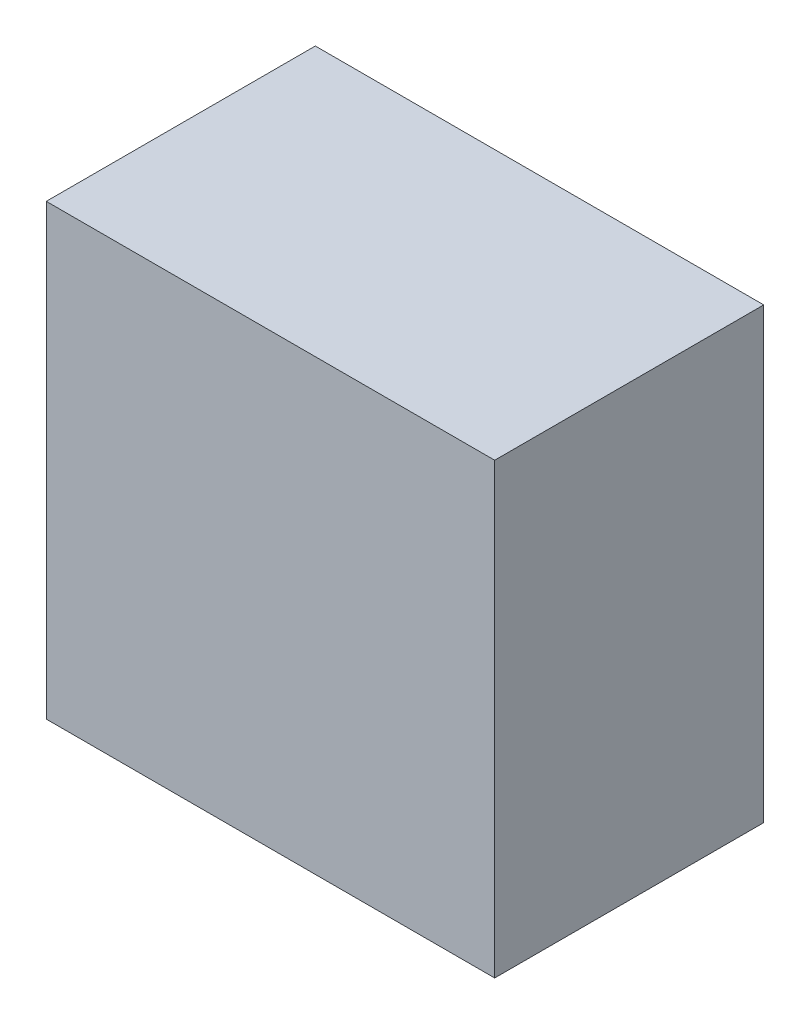
from build123d import *

# Parameters (mm, degrees)
SKETCH1_W           = 50
SKETCH1_H           = 50
BOSS_EXTRUDE1_DEPTH = 30


with BuildPart() as part:
    # Sketch1 → Boss-Extrude1 (new body)
    with BuildSketch(Plane.XY):
        Rectangle(SKETCH1_W, SKETCH1_H)
    extrude(amount=BOSS_EXTRUDE1_DEPTH)


solid = part.part
